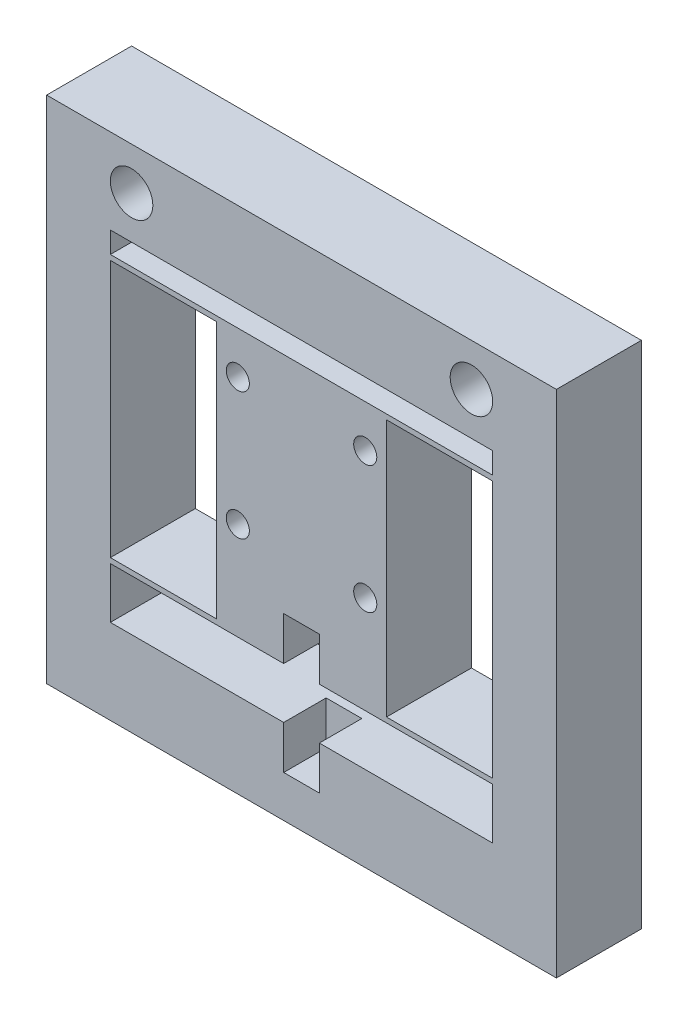
from build123d import *

# Parameters (mm, degrees)
SKETCH1_W                       = 76.2
SKETCH1_H                       = 76.2
BOSS_EXTRUDE1_DEPTH             = 6.35
SKETCH2_W                       = 57.15
SKETCH2_H                       = 3.175
SKETCH2_W_2                     = 15.875
SKETCH2_H_2                     = 38.481
SKETCH2_H_3                     = 7.62
CUT_EXTRUDE1_DEPTH              = 13.7
SKETCH3_W                       = 5.334
SKETCH3_H                       = 20.574
CUT_EXTRUDE2_DEPTH              = 6.35
F_1_4_0_25_DIAMETER_HOLE1_D     = 6.35
F_1_4_0_25_DIAMETER_HOLE1_DEPTH = 12.7
F_8_32_TAPPED_HOLE1_D           = 3.4544
F_8_32_TAPPED_HOLE1_DEPTH       = 12.7


with BuildPart() as part:
    # Sketch1 → Boss-Extrude1 (new body, symmetric)
    with BuildSketch(Plane.XY):
        Rectangle(SKETCH1_W, SKETCH1_H)
    extrude(amount=BOSS_EXTRUDE1_DEPTH, both=True)

    # Sketch2 → Cut-Extrude1 (cut, through all)
    with BuildSketch(Plane.XY.offset(6.35)):
        with Locations((0, 23.8125)):
            Rectangle(SKETCH2_W, SKETCH2_H)
        with Locations((20.6375, 2.2225)):
            Rectangle(SKETCH2_W_2, SKETCH2_H_2)
        with Locations((-20.6375, 2.2225)):
            Rectangle(SKETCH2_W_2, SKETCH2_H_2)
        with Locations((0, -21.59)):
            Rectangle(SKETCH2_W, SKETCH2_H_3)
    extrude(amount=-CUT_EXTRUDE1_DEPTH, mode=Mode.SUBTRACT)

    # Sketch3 → Cut-Extrude2 (cut)
    with BuildSketch(Plane.XY.offset(6.35)):
        with Locations((0, -21.59)):
            Rectangle(SKETCH3_W, SKETCH3_H)
    extrude(amount=-CUT_EXTRUDE2_DEPTH, mode=Mode.SUBTRACT)

    # 1/4 (0.25) Diameter Hole1
    with Locations(Plane.XY.offset(6.35)):
        with Locations((-25.4, 31.75), (25.4, 31.75)):
            Hole(F_1_4_0_25_DIAMETER_HOLE1_D / 2, depth=F_1_4_0_25_DIAMETER_HOLE1_DEPTH)

    # #8-32 Tapped Hole1
    with Locations(Plane.XY.offset(6.35)):
        with Locations((-9.525, 15.875), (9.525, 15.875), (9.525, -3.175), (-9.525, -3.175)):
            Hole(F_8_32_TAPPED_HOLE1_D / 2, depth=F_8_32_TAPPED_HOLE1_DEPTH)


solid = part.part
